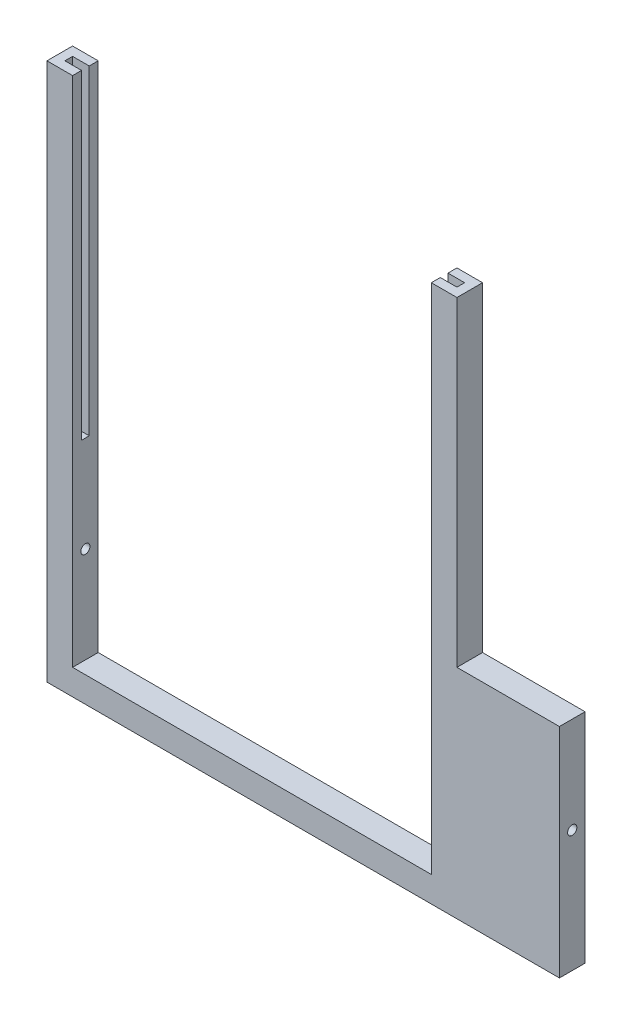
from build123d import *

# Parameters (mm, degrees)
BOSS_EXTRUDE1_DEPTH     = 2
SKETCH2_R               = 0.36
CUT_EXTRUDE1_DEPTH      = 1
CUT_EXTRUDE1_DEPTH_BACK = 41
BOSS_EXTRUDE2_DEPTH     = 25
BOSS_EXTRUDE3_DEPTH     = 25
CUT_EXTRUDE2_REACH      = 4
SKETCH5_W               = 8
SKETCH5_H               = 25


with BuildPart() as part:
    # Sketch1 → Boss-Extrude1 (new body)
    with BuildSketch(Plane.XY):
        Polygon((2, 17), (2, 2), (30, 2), (30, 17), (40, 17), (40, 0), (0, 0), (0, 17), align=None)
    extrude(amount=BOSS_EXTRUDE1_DEPTH)

    # Sketch2 → Cut-Extrude1 (cut, two sides)
    with BuildSketch(Plane(origin=(40, 0, 0), x_dir=(0, 0, -1), z_dir=(1, 0, 0))) as cut_extrude1_sk:
        with Locations((-1, 9.5)):
            Circle(SKETCH2_R)
    extrude(amount=CUT_EXTRUDE1_DEPTH, mode=Mode.SUBTRACT)
    extrude(cut_extrude1_sk.sketch, amount=-CUT_EXTRUDE1_DEPTH_BACK, mode=Mode.SUBTRACT)

    # Sketch3 → Boss-Extrude2 (add)
    with BuildSketch(Plane(origin=(0, 17, 0), x_dir=(1, 0, 0), z_dir=(0, 1, 0))):
        Polygon((0, -2), (2, -2), (2, -1.3), (0.7, -1.3), (0.7, -0.7), (2, -0.7), (2, 0), (0, 0), align=None)
    extrude(amount=BOSS_EXTRUDE2_DEPTH)

    # Sketch4 → Boss-Extrude3 (add)
    with BuildSketch(Plane(origin=(0, 17, 0), x_dir=(1, 0, 0), z_dir=(0, 1, 0))):
        Polygon((30, -2), (40, -2), (40, 0), (30, 0), (30, -0.7), (31.3, -0.7), (31.3, -1.3), (30, -1.3), align=None)
    extrude(amount=BOSS_EXTRUDE3_DEPTH)

    # Sketch5 → Cut-Extrude2 (cut, up to next)
    with BuildSketch(Plane.XY.offset(2), mode=Mode.PRIVATE) as cut_extrude2_sk1:
        with Locations((36, 29.5)):
            Rectangle(SKETCH5_W, SKETCH5_H)
    cut_extrude2_tool1 = extrude(cut_extrude2_sk1.sketch, amount=-CUT_EXTRUDE2_REACH, mode=Mode.PRIVATE) & part.part
    add(cut_extrude2_tool1.solids().sort_by_distance((36, 29.5, 2))[0], mode=Mode.SUBTRACT)


solid = part.part
